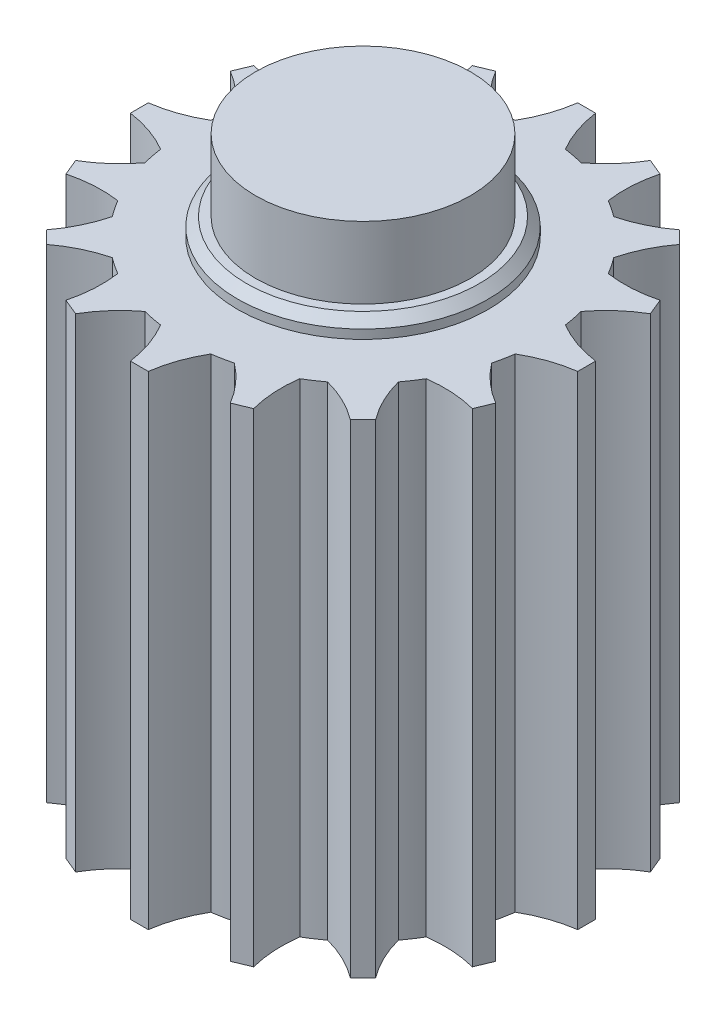
from build123d import *

# Parameters (mm, degrees)
BOSS_EXTRUDE1_DEPTH = 27
SKETCH2_R           = 6
BOSS_EXTRUDE2_DEPTH = 4
SKETCH4_R           = 7
BOSS_EXTRUDE3_DEPTH = 1
SKETCH5_R           = 6
BOSS_EXTRUDE4_DEPTH = 1
CHAMFER1_SIZE       = 0.5


with BuildPart() as part:
    # Sketch1 → Boss-Extrude1 (new body)
    with BuildSketch(Plane(origin=(0, 0, 0), x_dir=(1, 0, 0), z_dir=(0, 1, 0))):
        with BuildLine():
            Line((0.5, 12.489995997), (-0.5, 12.489995997))
            ThreePointArc((-0.5, 12.489995997), (-0.822089844, 11.151281888), (-1.4, 9.901515036))
            ThreePointArc((-1.4, 9.901515036), (-1.95090322, 9.807852804), (-2.495714414, 9.683563888))
            ThreePointArc((-2.495714414, 9.683563888), (-3.507898848, 10.61704126), (-4.317774772, 11.730593379))
            Line((-4.317774772, 11.730593379), (-5.241654305, 11.347909946))
            ThreePointArc((-5.241654305, 11.347909946), (-5.026922808, 9.987840934), (-5.082577105, 8.612050277))
            ThreePointArc((-5.082577105, 8.612050277), (-5.55570233, 8.314696123), (-6.011478932, 7.991377919))
            ThreePointArc((-6.011478932, 7.991377919), (-7.303841738, 8.466452345), (-8.478207476, 9.185314257))
            Line((-8.478207476, 9.185314257), (-9.185314257, 8.478207476))
            ThreePointArc((-9.185314257, 8.478207476), (-8.466452345, 7.303841738), (-7.991377919, 6.011478932))
            ThreePointArc((-7.991377919, 6.011478932), (-8.314696123, 5.55570233), (-8.612050277, 5.082577105))
            ThreePointArc((-8.612050277, 5.082577105), (-9.987840934, 5.026922808), (-11.347909946, 5.241654305))
            Line((-11.347909946, 5.241654305), (-11.730593379, 4.317774772))
            ThreePointArc((-11.730593379, 4.317774772), (-10.61704126, 3.507898848), (-9.683563888, 2.495714414))
            ThreePointArc((-9.683563888, 2.495714414), (-9.807852804, 1.95090322), (-9.901515036, 1.4))
            ThreePointArc((-9.901515036, 1.4), (-11.151281888, 0.822089844), (-12.489995997, 0.5))
            Line((-12.489995997, 0.5), (-12.489995997, -0.5))
            ThreePointArc((-12.489995997, -0.5), (-11.151281888, -0.822089844), (-9.901515036, -1.4))
            ThreePointArc((-9.901515036, -1.4), (-9.807852804, -1.95090322), (-9.683563888, -2.495714414))
            ThreePointArc((-9.683563888, -2.495714414), (-10.61704126, -3.507898848), (-11.730593379, -4.317774772))
            Line((-11.730593379, -4.317774772), (-11.347909946, -5.241654305))
            ThreePointArc((-11.347909946, -5.241654305), (-9.987840934, -5.026922808), (-8.612050277, -5.082577105))
            ThreePointArc((-8.612050277, -5.082577105), (-8.314696123, -5.55570233), (-7.991377919, -6.011478932))
            ThreePointArc((-7.991377919, -6.011478932), (-8.466452345, -7.303841738), (-9.185314257, -8.478207476))
            Line((-9.185314257, -8.478207476), (-8.478207476, -9.185314257))
            ThreePointArc((-8.478207476, -9.185314257), (-7.303841738, -8.466452345), (-6.011478932, -7.991377919))
            ThreePointArc((-6.011478932, -7.991377919), (-5.55570233, -8.314696123), (-5.082577105, -8.612050277))
            ThreePointArc((-5.082577105, -8.612050277), (-5.026922808, -9.987840934), (-5.241654305, -11.347909946))
            Line((-5.241654305, -11.347909946), (-4.317774772, -11.730593379))
            ThreePointArc((-4.317774772, -11.730593379), (-3.507898848, -10.61704126), (-2.495714414, -9.683563888))
            ThreePointArc((-2.495714414, -9.683563888), (-1.95090322, -9.807852804), (-1.4, -9.901515036))
            ThreePointArc((-1.4, -9.901515036), (-0.822089844, -11.151281888), (-0.5, -12.489995997))
            Line((-0.5, -12.489995997), (0.5, -12.489995997))
            ThreePointArc((0.5, -12.489995997), (0.822089844, -11.151281888), (1.4, -9.901515036))
            ThreePointArc((1.4, -9.901515036), (1.95090322, -9.807852804), (2.495714414, -9.683563888))
            ThreePointArc((2.495714414, -9.683563888), (3.507898848, -10.61704126), (4.317774772, -11.730593379))
            Line((4.317774772, -11.730593379), (5.241654305, -11.347909946))
            ThreePointArc((5.241654305, -11.347909946), (5.026922808, -9.987840934), (5.082577105, -8.612050277))
            ThreePointArc((5.082577105, -8.612050277), (5.55570233, -8.314696123), (6.011478932, -7.991377919))
            ThreePointArc((6.011478932, -7.991377919), (7.303841738, -8.466452345), (8.478207476, -9.185314257))
            Line((8.478207476, -9.185314257), (9.185314257, -8.478207476))
            ThreePointArc((9.185314257, -8.478207476), (8.466452345, -7.303841738), (7.991377919, -6.011478932))
            ThreePointArc((7.991377919, -6.011478932), (8.314696123, -5.55570233), (8.612050277, -5.082577105))
            ThreePointArc((8.612050277, -5.082577105), (9.987840934, -5.026922808), (11.347909946, -5.241654305))
            Line((11.347909946, -5.241654305), (11.730593379, -4.317774772))
            ThreePointArc((11.730593379, -4.317774772), (10.61704126, -3.507898848), (9.683563888, -2.495714414))
            ThreePointArc((9.683563888, -2.495714414), (9.807852804, -1.95090322), (9.901515036, -1.4))
            ThreePointArc((9.901515036, -1.4), (11.151281888, -0.822089844), (12.489995997, -0.5))
            Line((12.489995997, -0.5), (12.489995997, 0.5))
            ThreePointArc((12.489995997, 0.5), (11.151281888, 0.822089844), (9.901515036, 1.4))
            ThreePointArc((9.901515036, 1.4), (9.807852804, 1.95090322), (9.683563888, 2.495714414))
            ThreePointArc((9.683563888, 2.495714414), (10.61704126, 3.507898848), (11.730593379, 4.317774772))
            Line((11.730593379, 4.317774772), (11.347909946, 5.241654305))
            ThreePointArc((11.347909946, 5.241654305), (9.987840934, 5.026922808), (8.612050277, 5.082577105))
            ThreePointArc((8.612050277, 5.082577105), (8.314696123, 5.55570233), (7.991377919, 6.011478932))
            ThreePointArc((7.991377919, 6.011478932), (8.466452345, 7.303841738), (9.185314257, 8.478207476))
            Line((9.185314257, 8.478207476), (8.478207476, 9.185314257))
            ThreePointArc((8.478207476, 9.185314257), (7.303841738, 8.466452345), (6.011478932, 7.991377919))
            ThreePointArc((6.011478932, 7.991377919), (5.55570233, 8.314696123), (5.082577105, 8.612050277))
            ThreePointArc((5.082577105, 8.612050277), (5.026922808, 9.987840934), (5.241654305, 11.347909946))
            Line((5.241654305, 11.347909946), (4.317774772, 11.730593379))
            ThreePointArc((4.317774772, 11.730593379), (3.507898848, 10.61704126), (2.495714414, 9.683563888))
            ThreePointArc((2.495714414, 9.683563888), (1.95090322, 9.807852804), (1.4, 9.901515036))
            ThreePointArc((1.4, 9.901515036), (0.822089844, 11.151281888), (0.5, 12.489995997))
        make_face()
    extrude(amount=BOSS_EXTRUDE1_DEPTH)

    # Sketch2 → Boss-Extrude2 (add)
    with BuildSketch(Plane(origin=(0, 27, 0), x_dir=(1, 0, 0), z_dir=(0, 1, 0))):
        Circle(SKETCH2_R)
    extrude(amount=BOSS_EXTRUDE2_DEPTH)

    # Sketch4 → Boss-Extrude3 (add)
    with BuildSketch(Plane(origin=(0, 27, 0), x_dir=(1, 0, 0), z_dir=(0, 1, 0))):
        Circle(SKETCH4_R)
    extrude(amount=BOSS_EXTRUDE3_DEPTH)

    # Sketch5 → Boss-Extrude4 (add)
    with BuildSketch(Plane(origin=(0, 31, 0), x_dir=(1, 0, 0), z_dir=(0, 1, 0))):
        Circle(SKETCH5_R)
    extrude(amount=BOSS_EXTRUDE4_DEPTH)

    # Chamfer1
    chamfer1_edges = [part.edges().sort_by_distance(p)[0] for p in [
        (-7, 28, 0),
    ]]
    chamfer(chamfer1_edges, length=CHAMFER1_SIZE)


solid = part.part
